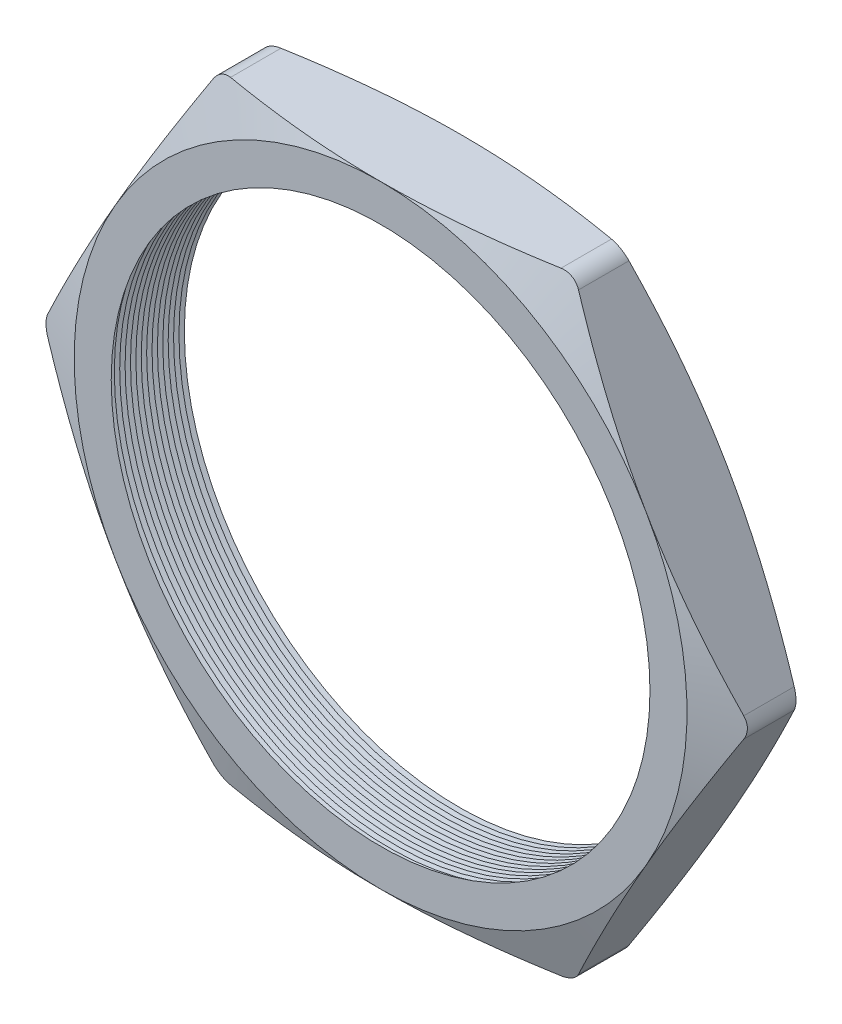
from build123d import *

# Parameters (mm, degrees)
SKETCH1_R          = 10.16
EXTRUDE1_DEPTH     = 3.048
FILLET1_R          = 0.762
SKETCH2_OUTSIDE_W  = 57.75
SKETCH2_OUTSIDE_H  = 54.41
SKETCH2_OUTSIDE_R  = 11.557
CUT_EXTRUDE1_DEPTH = 4.048
CUT_EXTRUDE1_DRAFT = -70
SKETCH3_OUTSIDE_W  = 57.75
SKETCH3_OUTSIDE_H  = 54.41
SKETCH3_OUTSIDE_R  = 11.557
CUT_EXTRUDE2_DEPTH = 4.0480001
CUT_EXTRUDE2_DRAFT = -70
LPATTERN1_COUNT    = 15
LPATTERN1_PITCH    = 0.2032


with BuildPart() as part:
    # Sketch1 → Extrude1 (new body)
    with BuildSketch(Plane.XY):
        Polygon((-13.344874122, 0), (-6.672437061, -11.557), (6.672437061, -11.557), (13.344874122, 0), (6.672437061, 11.557), (-6.672437061, 11.557), align=None)
        Circle(SKETCH1_R, mode=Mode.SUBTRACT)
    extrude(amount=EXTRUDE1_DEPTH)

    # Fillet1
    fillet1_edges = [part.edges().sort_by_distance(p)[0] for p in [
        (13.344874122, 0, 1.524),
        (6.672437061, -11.557, 1.524),
        (-6.672437061, -11.557, 1.524),
        (-13.344874122, 0, 1.524),
        (-6.672437061, 11.557, 1.524),
        (6.672437061, 11.557, 1.524),
    ]]
    fillet(fillet1_edges, radius=FILLET1_R)


with BuildPart() as cut_extrude1_tool:
    # Sketch2 outside → Cut-Extrude1 (with draft: the straight prism first)
    with BuildSketch(Plane.XY.offset(3.048)):
        Rectangle(SKETCH2_OUTSIDE_W, SKETCH2_OUTSIDE_H)
        Circle(SKETCH2_OUTSIDE_R, mode=Mode.SUBTRACT)
    extrude(amount=-CUT_EXTRUDE1_DEPTH)
    # Cut-Extrude1: the draft: its side faces are tilted about the plane it starts from
    cut_extrude1_sides = [cut_extrude1_tool.faces().sort_by_distance(p)[0] for p in [
        (0, -27.205, 1.024),
        (28.875, 0, 1.024),
        (0, 27.205, 1.024),
        (-28.875, 0, 1.024),
        (-11.557, 0, 1.024),
    ]]
    draft(cut_extrude1_sides, Plane.XY.offset(3.048), CUT_EXTRUDE1_DRAFT)


with BuildPart() as part_1:
    add(part.part)

    # Cut-Extrude1: cut by cut_extrude1_tool
    add(cut_extrude1_tool.part, mode=Mode.SUBTRACT)


with BuildPart() as cut_extrude2_tool:
    # Sketch3 outside → Cut-Extrude2 (with draft: the straight prism first)
    with BuildSketch(Plane(origin=(0, 0, 0), x_dir=(-1, 0, 0), z_dir=(0, 0, -1))):
        Rectangle(SKETCH3_OUTSIDE_W, SKETCH3_OUTSIDE_H)
        Circle(SKETCH3_OUTSIDE_R, mode=Mode.SUBTRACT)
    extrude(amount=-CUT_EXTRUDE2_DEPTH)
    # Cut-Extrude2: the draft: its side faces are tilted about the plane it starts from
    cut_extrude2_sides = [cut_extrude2_tool.faces().sort_by_distance(p)[0] for p in [
        (0, -27.205, 2.02400005),
        (-28.875, 0, 2.02400005),
        (0, 27.205, 2.02400005),
        (28.875, 0, 2.02400005),
        (11.557, 0, 2.02400005),
    ]]
    draft(cut_extrude2_sides, Plane(origin=(0, 0, 0), x_dir=(-1, 0, 0), z_dir=(0, 0, -1)), CUT_EXTRUDE2_DRAFT)


with BuildPart() as part_2:
    add(part_1.part)

    # Cut-Extrude2: cut by cut_extrude2_tool
    add(cut_extrude2_tool.part, mode=Mode.SUBTRACT)

    # Sketch4 → Cut-Revolve1 (revolve, cut)
    with BuildSketch(Plane(origin=(0, 0, 0), x_dir=(1, 0, 0), z_dir=(0, 1, 0))):
        Polygon((-10.16, -3.048), (-10.16, -2.608059095), (-10.541, -2.828029547), align=None)
    cut_revolve1 = revolve(axis=Axis((0, 0, 3.048), (0, 0, -1)), mode=Mode.SUBTRACT)

    # LPattern1: Cut-Revolve1 ×15
    with Locations(*[(0, 0, -i * LPATTERN1_PITCH) for i in range(1, LPATTERN1_COUNT)]):
        add(cut_revolve1, mode=Mode.SUBTRACT)


solid = part_2.part
